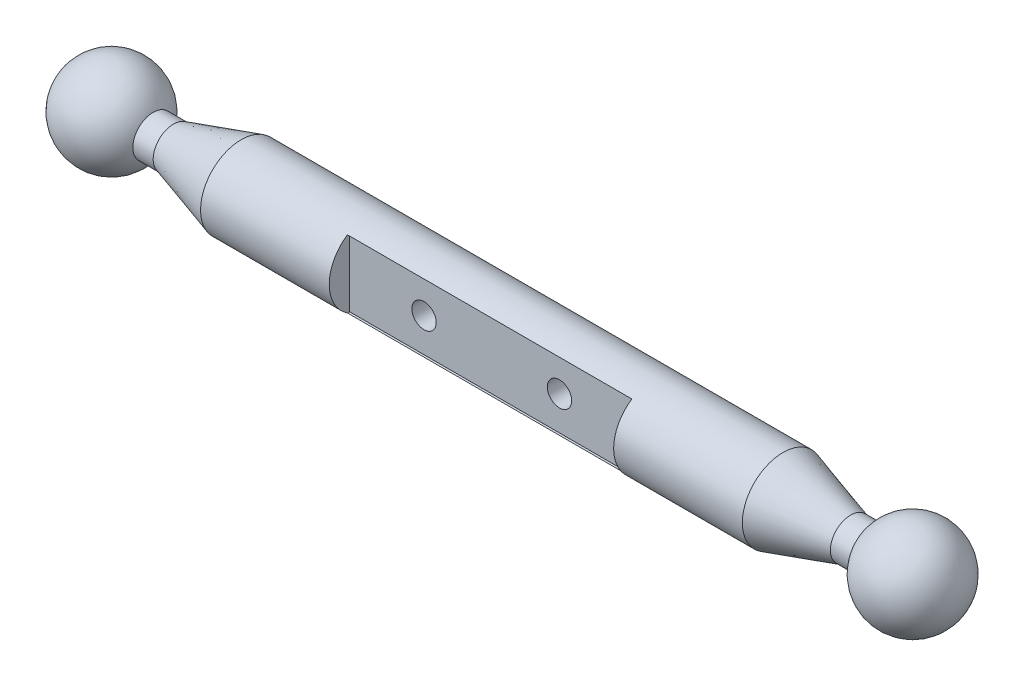
from build123d import *

# Parameters (mm, degrees)
SKETCH4_W          = 210
SKETCH4_H          = 50
CUT_EXTRUDE2_DEPTH = 15
SKETCH5_R          = 9
CUT_EXTRUDE3_DEPTH = 80
DOME1_FACE_RADIUS  = 15
DOME1_HEIGHT       = 65
DOME2_FACE_RADIUS  = 15
DOME2_HEIGHT       = 65


with BuildPart() as part:
    # Sketch2 → Revolve1 (revolve)
    with BuildSketch(Plane.XY):
        Polygon((-265, 0), (265, 0), (265, 15), (250, 15), (200, 30), (-200, 30), (-250, 15), (-265, 15), align=None)
    revolve(axis=Axis((-265, 0, 0), (1, 0, 0)))

    # Sketch4 → Cut-Extrude2 (cut)
    with BuildSketch(Plane.XY.offset(30)):
        Rectangle(SKETCH4_W, SKETCH4_H)
    extrude(amount=-CUT_EXTRUDE2_DEPTH, mode=Mode.SUBTRACT)

    # Sketch5 → Cut-Extrude3 (cut)
    with BuildSketch(Plane.XY.offset(30)):
        with Locations((50, 0)):
            Circle(SKETCH5_R)
        with Locations((-50, 0)):
            Circle(SKETCH5_R)
    extrude(amount=-CUT_EXTRUDE3_DEPTH, mode=Mode.SUBTRACT)

    # Dome1: a dome of height H over a round flat face of radius A is a cap of a sphere of radius (A * A + H * H) / (2 * H)
    dome1_r = (DOME1_FACE_RADIUS * DOME1_FACE_RADIUS + DOME1_HEIGHT * DOME1_HEIGHT) / (2 * DOME1_HEIGHT)
    dome1_base = Plane((265, 0, 0), z_dir=(1, 0, 0))
    with Locations(dome1_base.offset(DOME1_HEIGHT - dome1_r)):
        dome1_ball = Sphere(dome1_r, mode=Mode.PRIVATE)
    add(split(dome1_ball, bisect_by=dome1_base, keep=Keep.TOP, mode=Mode.PRIVATE))

    # Dome2: a dome of height H over a round flat face of radius A is a cap of a sphere of radius (A * A + H * H) / (2 * H)
    dome2_r = (DOME2_FACE_RADIUS * DOME2_FACE_RADIUS + DOME2_HEIGHT * DOME2_HEIGHT) / (2 * DOME2_HEIGHT)
    dome2_base = Plane((-265, 0, 0), z_dir=(-1, 0, 0))
    with Locations(dome2_base.offset(DOME2_HEIGHT - dome2_r)):
        dome2_ball = Sphere(dome2_r, mode=Mode.PRIVATE)
    add(split(dome2_ball, bisect_by=dome2_base, keep=Keep.TOP, mode=Mode.PRIVATE))


solid = part.part
